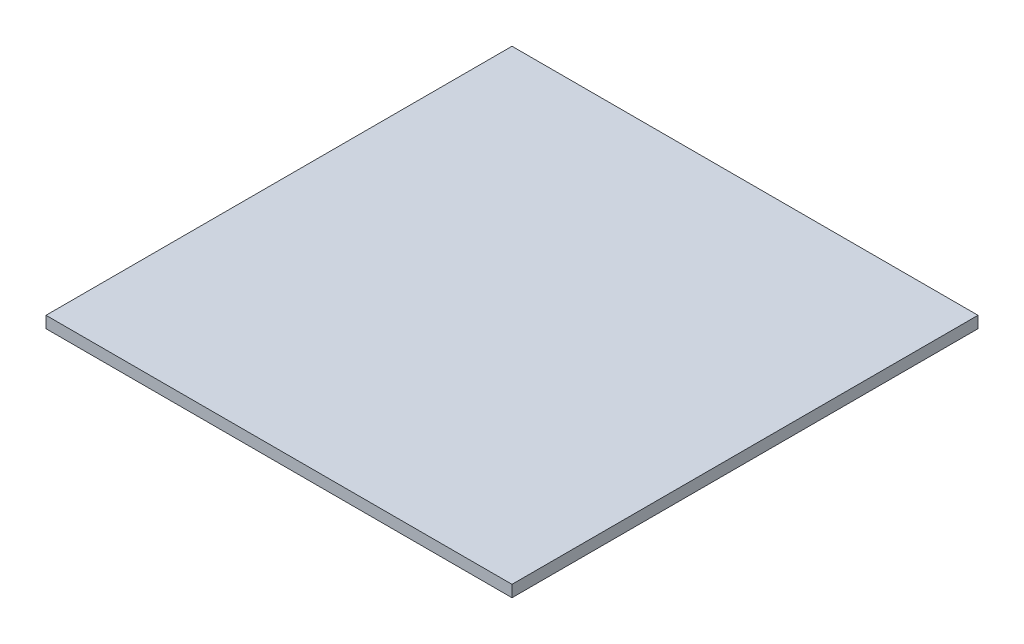
from build123d import *

# Parameters (mm, degrees)
SKETCH_1_W      = 200
SKETCH_1_H      = 200
EXTRUDE_1_DEPTH = 5


with BuildPart() as part:
    # 草图1 → 凸台-拉伸1 (new body)
    with BuildSketch(Plane(origin=(0, 0, 0), x_dir=(1, 0, 0), z_dir=(0, 1, 0))):
        Rectangle(SKETCH_1_W, SKETCH_1_H)
    extrude(amount=EXTRUDE_1_DEPTH)


solid = part.part
